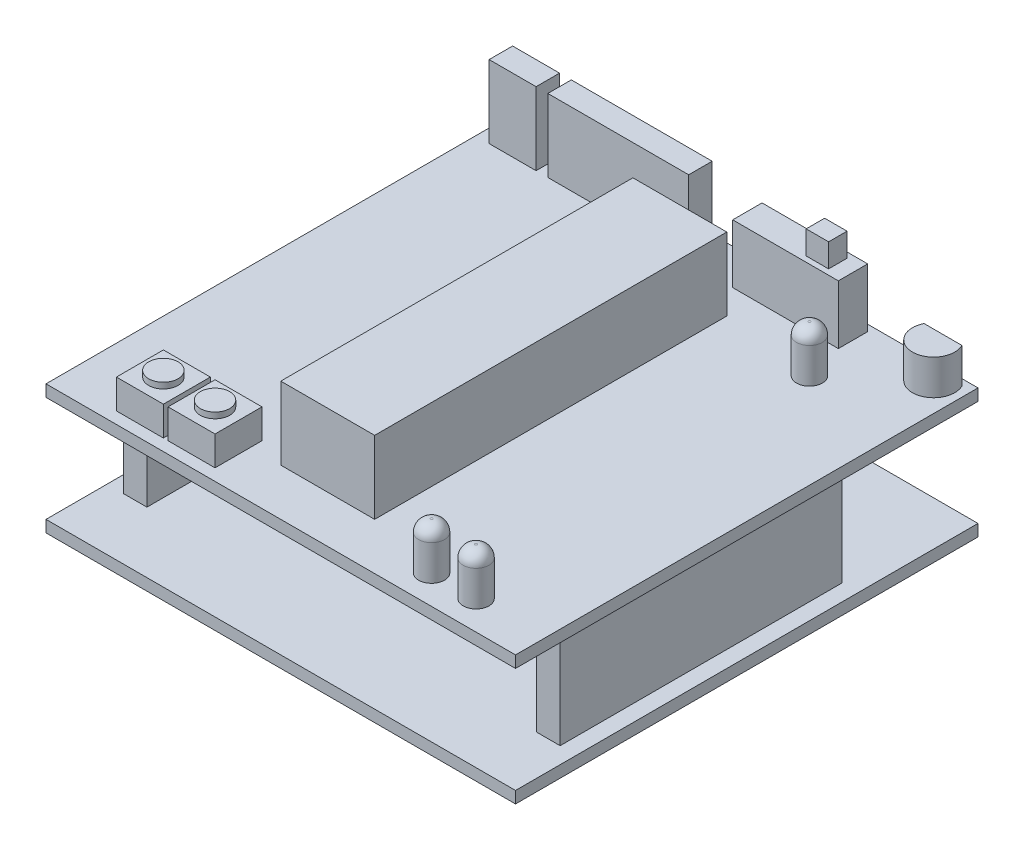
from build123d import *

# Parameters (mm, degrees)
SKETCH1_W            = 50.8
SKETCH1_H            = 50.038
BOSS_EXTRUDE1_DEPTH  = 1.27
SKETCH2_W            = 2.54
SKETCH2_H            = 30.48
BOSS_EXTRUDE2_DEPTH  = 11.43
SKETCH3_W            = 10.16
SKETCH3_H            = 20.32
BOSS_EXTRUDE3_DEPTH  = 3.81
SKETCH4_W            = 50.8
SKETCH4_H            = 50.038
BOSS_EXTRUDE4_DEPTH  = 1.27
SKETCH5_W            = 10.16
SKETCH5_H            = 38.1
SKETCH5_W_2          = 5.08
SKETCH5_H_2          = 2.54
SKETCH5_W_3          = 15.24
BOSS_EXTRUDE5_DEPTH  = 7.874
SKETCH5_3_W          = 5.08
SKETCH5_3_H          = 5.08
BOSS_EXTRUDE6_DEPTH  = 3.175
SKETCH5_4_R          = 1.397
BOSS_EXTRUDE7_DEPTH  = 5.08
SKETCH5_5_W          = 11.43
SKETCH5_5_H          = 3.175
BOSS_EXTRUDE8_DEPTH  = 6.35
BOSS_EXTRUDE9_DEPTH  = 3.81
FILLET1_R            = 1.27
SKETCH8_R            = 1.5875
BOSS_EXTRUDE10_DEPTH = 0.635
SKETCH9_W            = 2.427127008
SKETCH9_H            = 1.995592696
BOSS_EXTRUDE11_DEPTH = 2.54


with BuildPart() as part:
    # Sketch1 → Boss-Extrude1 (new body)
    with BuildSketch(Plane(origin=(0, 0, 0), x_dir=(1, 0, 0), z_dir=(0, 1, 0))):
        Rectangle(SKETCH1_W, SKETCH1_H)
    extrude(amount=BOSS_EXTRUDE1_DEPTH)

    # Sketch2 → Boss-Extrude2 (add)
    with BuildSketch(Plane(origin=(0, 1.27, 0), x_dir=(1, 0, 0), z_dir=(0, 1, 0))):
        with Locations((-22.352, -3.175)):
            Rectangle(SKETCH2_W, SKETCH2_H)
        with Locations((22.352, -3.175)):
            Rectangle(SKETCH2_W, SKETCH2_H)
    extrude(amount=BOSS_EXTRUDE2_DEPTH)

    # Sketch3 → Boss-Extrude3 (add)
    with BuildSketch(Plane(origin=(0, 1.27, 0), x_dir=(1, 0, 0), z_dir=(0, 1, 0))):
        with Locations((0, 13.335)):
            Rectangle(SKETCH3_W, SKETCH3_H)
    extrude(amount=BOSS_EXTRUDE3_DEPTH)

    # Sketch4 → Boss-Extrude4 (add)
    with BuildSketch(Plane(origin=(0, 12.7, 0), x_dir=(1, 0, 0), z_dir=(0, 1, 0))):
        Rectangle(SKETCH4_W, SKETCH4_H)
    extrude(amount=BOSS_EXTRUDE4_DEPTH)

    # Sketch5 → Boss-Extrude5 (add)
    with BuildSketch(Plane(origin=(0, 13.97, 0), x_dir=(1, 0, 0), z_dir=(0, 1, 0))):
        with Locations((0, -0.889)):
            Rectangle(SKETCH5_W, SKETCH5_H)
        with Locations((-21.396399328, 22.733)):
            Rectangle(SKETCH5_W_2, SKETCH5_H_2)
        with Locations((-9.966399328, 22.733)):
            Rectangle(SKETCH5_W_3, SKETCH5_H_2)
    extrude(amount=BOSS_EXTRUDE5_DEPTH)

    # Sketch5_3 → Boss-Extrude6 (add)
    with BuildSketch(Plane(origin=(0, 13.97, 0), x_dir=(1, 0, 0), z_dir=(0, 1, 0))):
        with Locations((-10.922, -21.209)):
            Rectangle(SKETCH5_3_W, SKETCH5_3_H)
        with Locations((-16.51, -21.209)):
            Rectangle(SKETCH5_3_W, SKETCH5_3_H)
    extrude(amount=BOSS_EXTRUDE6_DEPTH)

    # Sketch5_4 → Boss-Extrude7 (add)
    with BuildSketch(Plane(origin=(0, 13.97, 0), x_dir=(1, 0, 0), z_dir=(0, 1, 0))):
        with Locations((13.16676441, -21.867024383)):
            Circle(SKETCH5_4_R)
        with Locations((17.978093258, -21.867024383)):
            Circle(SKETCH5_4_R)
        with Locations((15.135118943, 17.046813881)):
            Circle(SKETCH5_4_R)
    extrude(amount=BOSS_EXTRUDE7_DEPTH)

    # Sketch5_5 → Boss-Extrude8 (add)
    with BuildSketch(Plane(origin=(0, 13.97, 0), x_dir=(1, 0, 0), z_dir=(0, 1, 0))):
        with Locations((8.448600672, 22.733)):
            Rectangle(SKETCH5_5_W, SKETCH5_5_H)
    extrude(amount=BOSS_EXTRUDE8_DEPTH)

    # Sketch5_6 → Boss-Extrude9 (add)
    with BuildSketch(Plane(origin=(0, 13.97, 0), x_dir=(1, 0, 0), z_dir=(0, 1, 0))):
        with BuildLine():
            Line((20.260877265, 24.3205), (24.356504201, 24.3205))
            ThreePointArc((24.356504201, 24.3205), (22.308690733, 21.0185), (20.260877265, 24.3205))
        make_face()
    extrude(amount=BOSS_EXTRUDE9_DEPTH)

    # Fillet1
    fillet1_edges = [part.edges().sort_by_distance(p)[0] for p in [
        (16.581093258, 19.05, 21.867024383),
        (11.76976441, 19.05, 21.867024383),
        (13.738118943, 19.05, -17.046813881),
    ]]
    fillet(fillet1_edges, radius=FILLET1_R)

    # Sketch8 → Boss-Extrude10 (add)
    with BuildSketch(Plane(origin=(0, 17.145, 0), x_dir=(1, 0, 0), z_dir=(0, 1, 0))):
        with Locations((-16.51, -21.209)):
            Circle(SKETCH8_R)
        with Locations((-10.922, -21.209)):
            Circle(SKETCH8_R)
    extrude(amount=BOSS_EXTRUDE10_DEPTH)

    # Sketch9 → Boss-Extrude11 (add)
    with BuildSketch(Plane(origin=(0, 20.32, 0), x_dir=(1, 0, 0), z_dir=(0, 1, 0))):
        with Locations((11.306100672, 22.733)):
            Rectangle(SKETCH9_W, SKETCH9_H)
    extrude(amount=BOSS_EXTRUDE11_DEPTH)


solid = part.part
